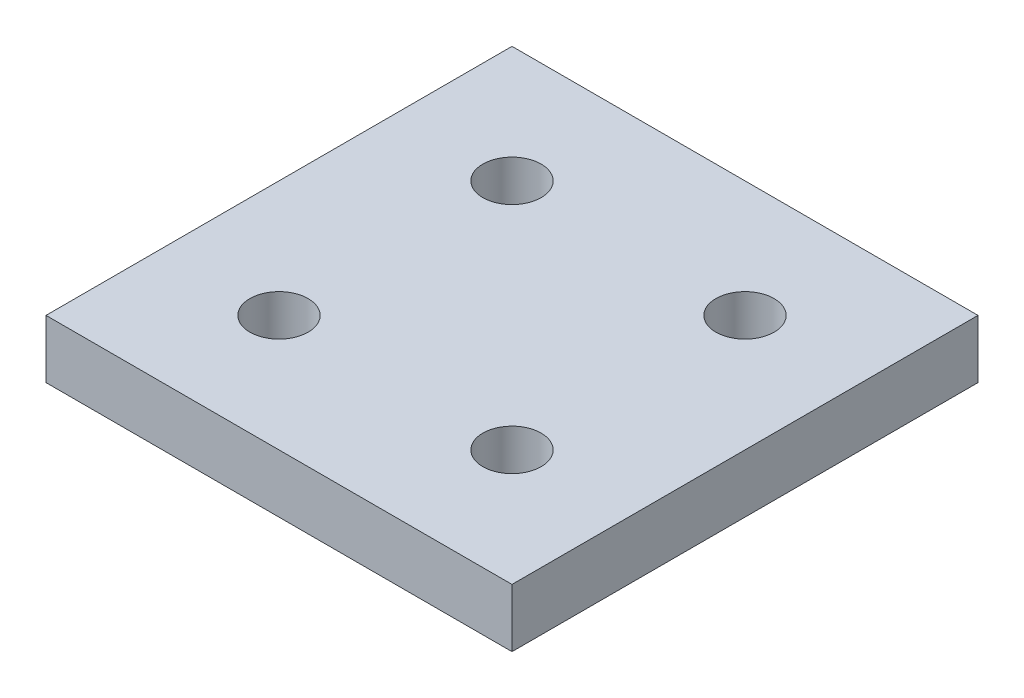
from build123d import *

# Parameters (mm, degrees)
SKETCH1_W                  = 101.6
SKETCH1_H                  = 101.6
BOSS_EXTRUDE1_DEPTH        = 12.7
F_1_2_0_5_DIAMETER_HOLE1_D = 12.7


with BuildPart() as part:
    # Sketch1 → Boss-Extrude1 (new body)
    with BuildSketch(Plane(origin=(0, 0, 0), x_dir=(1, 0, 0), z_dir=(0, 1, 0))):
        with Locations((50.8, 50.8)):
            Rectangle(SKETCH1_W, SKETCH1_H)
    extrude(amount=BOSS_EXTRUDE1_DEPTH)

    # 1/2 (0.5) Diameter Hole1 (through all)
    with Locations(Plane(origin=(25.4, 12.7, -25.4), x_dir=(0, 0, 1), z_dir=(0, 1, 0))):
        with Locations((0, 0), (-50.8, 0), (-50.8, 50.8), (0, 50.8)):
            Hole(F_1_2_0_5_DIAMETER_HOLE1_D / 2)


solid = part.part
